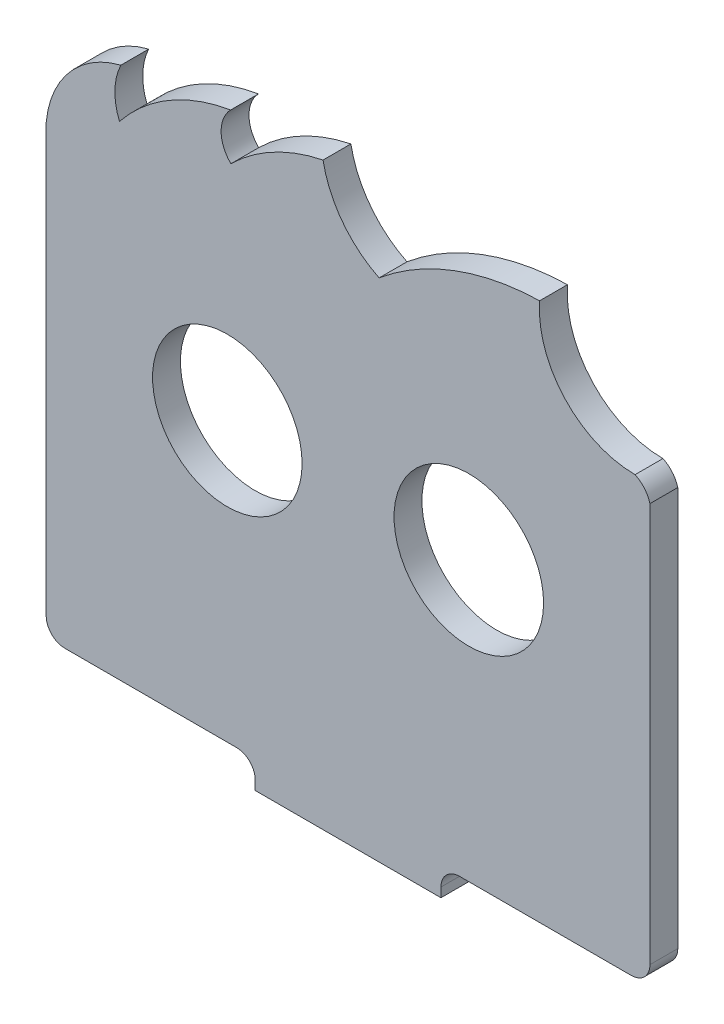
from build123d import *

# Parameters (mm, degrees)
CROQUIS1_R              = 8.05
SALIENTE_EXTRUIR1_DEPTH = 3
CROQUIS2_W              = 20
CROQUIS2_H              = 3
SALIENTE_EXTRUIR2_DEPTH = 11
CROQUIS3_R              = 1.5
CORTAR_EXTRUIR1_DEPTH   = 3
REDONDEO2_R             = 2
CROQUIS4_R              = 2.25
CORTAR_EXTRUIR2_DEPTH   = 1


with BuildPart() as part:
    # Croquis1 → Saliente-Extruir1 (new body)
    with BuildSketch(Plane.XY):
        with BuildLine():
            Line((-30.938838255, -8.045633461), (-10.938838255, -8.045633461))
            Line((-10.938838255, -8.045633461), (-10.938838255, -7.045633461))
            ThreePointArc((-10.938838255, -7.045633461), (-10.353051818, -5.631419899), (-8.938838255, -5.045633461))
            Line((-8.938838255, -5.045633461), (9.549778797, -5.045633461))
            ThreePointArc((9.549778797, -5.045633461), (10.972041616, -4.456512912), (11.561162165, -3.034250093))
            Line((11.561162165, -3.034250093), (11.561162165, 39.954366539))
            ThreePointArc((11.561162165, 39.954366539), (10.968432365, 41.078847271), (9.963268776, 41.856942185))
            ThreePointArc((9.963268776, 41.856942185), (2.408997489, 45.151653306), (-0.316073105, 52.929578886))
            ThreePointArc((-0.316073105, 52.929578886), (-9.509697497, 51.145023059), (-17.59663302, 46.421799285))
            ThreePointArc((-17.59663302, 46.421799285), (-21.556040731, 49.695374216), (-23.633455433, 54.394049605))
            ThreePointArc((-23.633455433, 54.394049605), (-28.98150225, 52.459242343), (-33.559009638, 49.084111234))
            ThreePointArc((-33.559009638, 49.084111234), (-34.606059472, 51.579310047), (-33.582063508, 54.084058086))
            ThreePointArc((-33.582063508, 54.084058086), (-40.220863613, 51.667488325), (-45.549660534, 47.028803207))
            ThreePointArc((-45.549660534, 47.028803207), (-46.044361143, 49.705869681), (-45.402636247, 52.35154592))
            ThreePointArc((-45.402636247, 52.35154592), (-50.909137078, 48.962948767), (-53.438838255, 43.012759358))
            Line((-53.438838255, 43.012759358), (-53.438838255, -2.988324387))
            ThreePointArc((-53.438838255, -2.988324387), (-52.861811755, -4.429826639), (-51.430168576, -5.030897458))
            Line((-51.430168576, -5.030897458), (-32.937399988, -5.044196229))
            ThreePointArc((-32.937399988, -5.044196229), (-31.52411628, -5.630490745), (-30.938838255, -7.044195711))
            Line((-30.938838255, -7.044195711), (-30.938838255, -8.045633461))
        make_face()
        with Locations((-7.938838255, 24.954366539)):
            Circle(CROQUIS1_R, mode=Mode.SUBTRACT)
        with Locations((-33.938838255, 24.954366539)):
            Circle(CROQUIS1_R, mode=Mode.SUBTRACT)
    extrude(amount=SALIENTE_EXTRUIR1_DEPTH)

    # Croquis2 → Saliente-Extruir2 (add)
    with BuildSketch(Plane.XY.offset(3)):
        with Locations((-20.938838255, -6.545633461)):
            Rectangle(CROQUIS2_W, CROQUIS2_H)
    extrude(amount=-SALIENTE_EXTRUIR2_DEPTH)

    # Croquis3 → Cortar-Extruir1 (cut)
    with BuildSketch(Plane(origin=(0, -5.045633461, 0), x_dir=(1, 0, 0), z_dir=(0, 1, 0))):
        with Locations((-14.938838255, 3.5)):
            Circle(CROQUIS3_R)
        with Locations((-26.938838255, 3.5)):
            Circle(CROQUIS3_R)
    extrude(amount=-CORTAR_EXTRUIR1_DEPTH, mode=Mode.SUBTRACT)

    # Redondeo2
    redondeo2_edges = [part.edges().sort_by_distance(p)[0] for p in [
        (-30.938838255, -6.545633461, -8),
        (-10.938838255, -6.545633461, -8),
    ]]
    fillet(redondeo2_edges, radius=REDONDEO2_R)

    # Croquis4 → Cortar-Extruir2 (cut)
    with BuildSketch(Plane(origin=(0, -5.045633461, 0), x_dir=(1, 0, 0), z_dir=(0, 1, 0))):
        with Locations((-26.938838255, 3.5)):
            Circle(CROQUIS4_R)
        with Locations((-14.938838255, 3.5)):
            Circle(CROQUIS4_R)
    extrude(amount=-CORTAR_EXTRUIR2_DEPTH, mode=Mode.SUBTRACT)


solid = part.part
